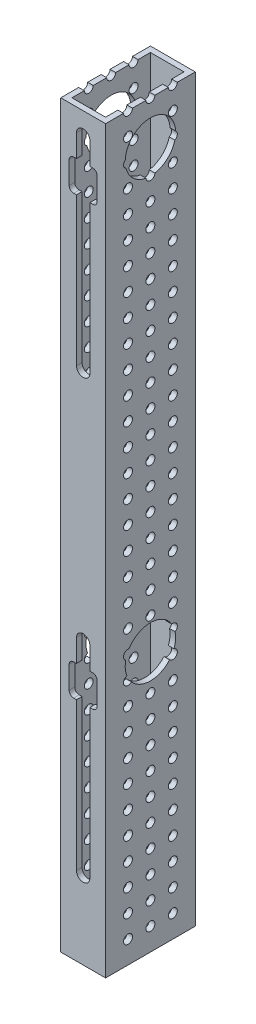
from build123d import *

# Parameters (mm, degrees)
SKETCH1_W            = 25.4
SKETCH1_H            = 50.8
BOSS_EXTRUDE1_DEPTH  = 419.1
SHELL1_T             = -3.175
CUT_EXTRUDE1_DEPTH   = 3.175
SKETCH3_R            = 14.2875
CUT_EXTRUDE2_DEPTH   = 26.4
CUT_EXTRUDE3_DEPTH   = 3.175
LPATTERN1_COUNT      = 2
LPATTERN1_PITCH      = 247.65
SKETCH6_R            = 2.54
CUT_EXTRUDE4_DEPTH   = 26.4
LPATTERN2_COUNT      = 33
LPATTERN2_PITCH      = 12.7
LPATTERN2_COUNT_DIR2 = 3
LPATTERN2_PITCH_DIR2 = 12.7


with BuildPart() as part:
    # Sketch1 → Boss-Extrude1 (new body)
    with BuildSketch(Plane(origin=(0, 0, 0), x_dir=(1, 0, 0), z_dir=(0, 1, 0))):
        with Locations((12.7, 25.4)):
            Rectangle(SKETCH1_W, SKETCH1_H)
    extrude(amount=BOSS_EXTRUDE1_DEPTH)

    # Shell1
    shell1_openings = [part.faces().sort_by_distance(p)[0] for p in [
        (12.7, 419.1, -25.4),
        (12.7, 0, -25.4),
    ]]
    offset(amount=SHELL1_T, openings=shell1_openings, kind=Kind.INTERSECTION)

    # Sketch2 → Cut-Extrude1 (cut)
    with BuildSketch(Plane.XY):
        with BuildLine():
            Line((16.51, 406.4), (16.51, 292.1))
            ThreePointArc((16.51, 292.1), (12.7, 288.29), (8.89, 292.1))
            Line((8.89, 292.1), (8.89, 406.4))
            ThreePointArc((8.89, 406.4), (12.7, 410.21), (16.51, 406.4))
        make_face()
    cut_extrude1 = extrude(amount=-CUT_EXTRUDE1_DEPTH, mode=Mode.SUBTRACT)

    # Sketch3 → Cut-Extrude2 (cut, through all)
    with BuildSketch(Plane(origin=(25.4, 0, 0), x_dir=(0, 0, -1), z_dir=(1, 0, 0))):
        with Locations((25.4, 394.97)):
            Circle(SKETCH3_R)
    cut_extrude2 = extrude(amount=-CUT_EXTRUDE2_DEPTH, mode=Mode.SUBTRACT)

    # Sketch4 → Cut-Extrude3 (cut)
    with BuildSketch(Plane.XY):
        with BuildLine():
            Line((16.51, 393.7), (18.0975, 393.7))
            ThreePointArc((18.0975, 393.7), (19.893551224, 392.956051224), (20.6375, 391.16))
            Line((20.6375, 391.16), (20.6375, 378.46))
            ThreePointArc((20.6375, 378.46), (19.893551224, 376.663948776), (18.0975, 375.92))
            Line((18.0975, 375.92), (16.51, 375.92))
            Line((16.51, 375.92), (8.89, 375.92))
            Line((8.89, 375.92), (7.3025, 375.92))
            ThreePointArc((7.3025, 375.92), (5.506448776, 376.663948776), (4.7625, 378.46))
            Line((4.7625, 378.46), (4.7625, 391.16))
            ThreePointArc((4.7625, 391.16), (5.506448776, 392.956051224), (7.3025, 393.7))
            Line((7.3025, 393.7), (8.89, 393.7))
            Line((8.89, 393.7), (16.51, 393.7))
        make_face()
    cut_extrude3 = extrude(amount=-CUT_EXTRUDE3_DEPTH, mode=Mode.SUBTRACT)

    # LPattern1: Cut-Extrude1, Cut-Extrude2, Cut-Extrude3 ×2
    with Locations(*[(0, -i * LPATTERN1_PITCH, 0) for i in range(1, LPATTERN1_COUNT)]):
        add(cut_extrude1, mode=Mode.SUBTRACT)
        add(cut_extrude2, mode=Mode.SUBTRACT)
        add(cut_extrude3, mode=Mode.SUBTRACT)

    # Sketch6 → Cut-Extrude4 (cut, through all)
    with BuildSketch(Plane.ZY):
        with Locations((-38.1, 12.7)):
            Circle(SKETCH6_R)
    cut_extrude4 = extrude(amount=-CUT_EXTRUDE4_DEPTH, mode=Mode.SUBTRACT)

    # LPattern2: Cut-Extrude4 33 × 3
    with Locations(*[(0, i * LPATTERN2_PITCH, j * LPATTERN2_PITCH_DIR2) for i in range(LPATTERN2_COUNT) for j in range(LPATTERN2_COUNT_DIR2) if (i, j) != (0, 0)]):
        add(cut_extrude4, mode=Mode.SUBTRACT)


solid = part.part
